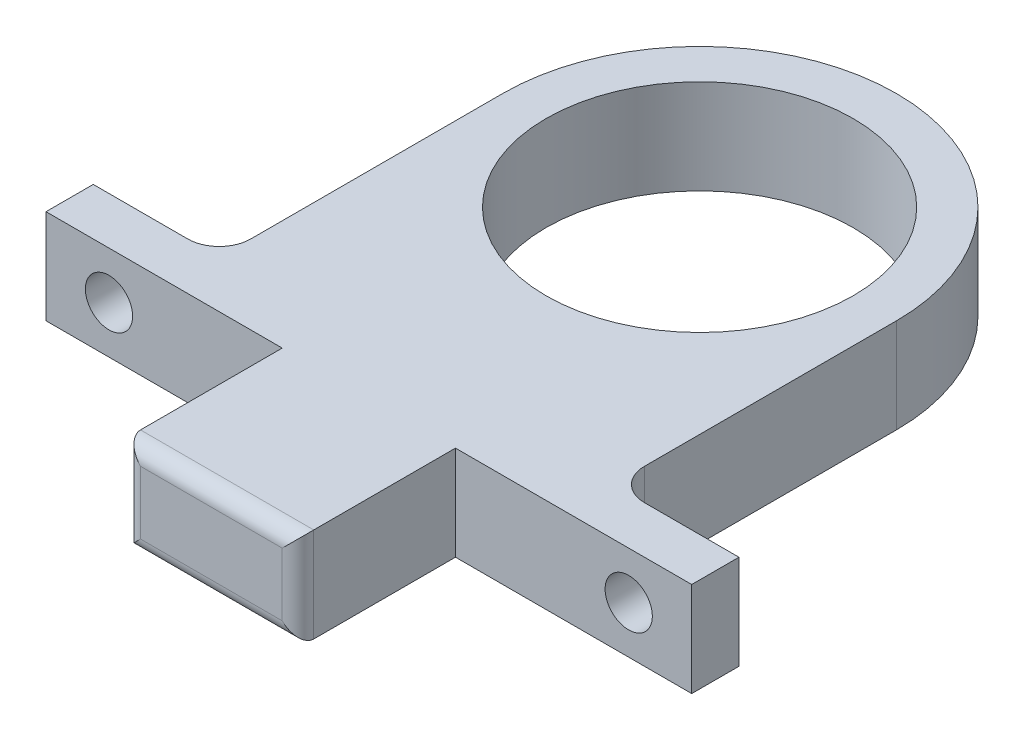
from build123d import *

# Parameters (mm, degrees)
CROQUIS1_R              = 9.75
SALIENTE_EXTRUIR1_DEPTH = 6
CROQUIS2_R              = 1.5
CORTAR_EXTRUIR1_DEPTH   = 6
CROQUIS3_R              = 3
CORTAR_EXTRUIR2_DEPTH   = 6
REDONDEO1_R             = 1


with BuildPart() as part:
    # Croquis1 → Saliente-Extruir1 (new body)
    with BuildSketch(Plane(origin=(0, 0, 0), x_dir=(1, 0, 0), z_dir=(0, 1, 0))):
        with BuildLine():
            ThreePointArc((12.5, 0), (0, 12.5), (-12.5, 0))
            Line((-12.5, 0), (-12.5, -16))
            ThreePointArc((-12.5, -16), (-13.085786438, -17.414213562), (-14.5, -18))
            Line((-14.5, -18), (-20.5, -18))
            Line((-20.5, -18), (-20.5, -21))
            Line((-20.5, -21), (-5.5, -21))
            Line((-5.5, -21), (-5.5, -31))
            Line((-5.5, -31), (5.5, -31))
            Line((5.5, -31), (5.5, -21))
            Line((5.5, -21), (20.5, -21))
            Line((20.5, -21), (20.5, -18))
            Line((20.5, -18), (14.5, -18))
            ThreePointArc((14.5, -18), (13.085786438, -17.414213562), (12.5, -16))
            Line((12.5, -16), (12.5, 0))
        make_face()
        Circle(CROQUIS1_R, mode=Mode.SUBTRACT)
    extrude(amount=SALIENTE_EXTRUIR1_DEPTH)

    # Croquis2 → Cortar-Extruir1 (cut)
    with BuildSketch(Plane.XY.offset(21)):
        with Locations((-16.5, 3)):
            Circle(CROQUIS2_R)
        with Locations((16.5, 3)):
            Circle(CROQUIS2_R)
    extrude(amount=-CORTAR_EXTRUIR1_DEPTH, mode=Mode.SUBTRACT)

    # Croquis3 → Cortar-Extruir2 (cut)
    with BuildSketch(Plane(origin=(0, 0, 18), x_dir=(-1, 0, 0), z_dir=(0, 0, -1))):
        with Locations((-16.5, 3)):
            Circle(CROQUIS3_R)
        with Locations((16.5, 3)):
            Circle(CROQUIS3_R)
    extrude(amount=CORTAR_EXTRUIR2_DEPTH, mode=Mode.SUBTRACT)

    # Redondeo1
    redondeo1_edges = [part.edges().sort_by_distance(p)[0] for p in [
        (5.5, 3, 31),
        (-5.5, 3, 31),
        (0, 6, 31),
        (0, 0, 31),
    ]]
    fillet(redondeo1_edges, radius=REDONDEO1_R)


solid = part.part
